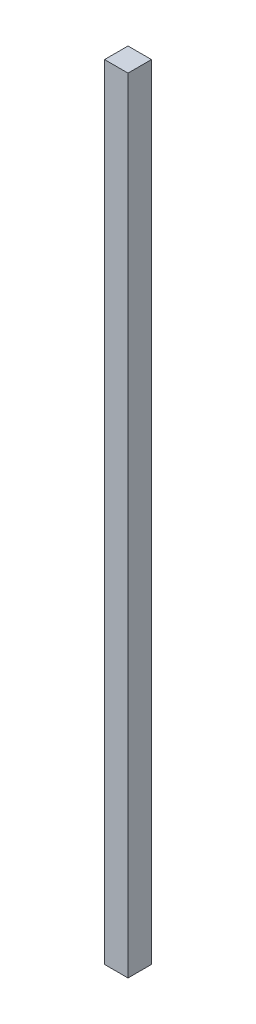
from build123d import *

# Parameters (mm, degrees)
SKETCH_1_W      = 10
SKETCH_1_H      = 10
EXTRUDE_1_DEPTH = 334


with BuildPart() as part:
    # Эскиз1 → Бобышка-Вытянуть1 (new body)
    with BuildSketch(Plane(origin=(0, 0, 0), x_dir=(1, 0, 0), z_dir=(0, 1, 0))):
        Rectangle(SKETCH_1_W, SKETCH_1_H)
    extrude(amount=EXTRUDE_1_DEPTH)


solid = part.part
